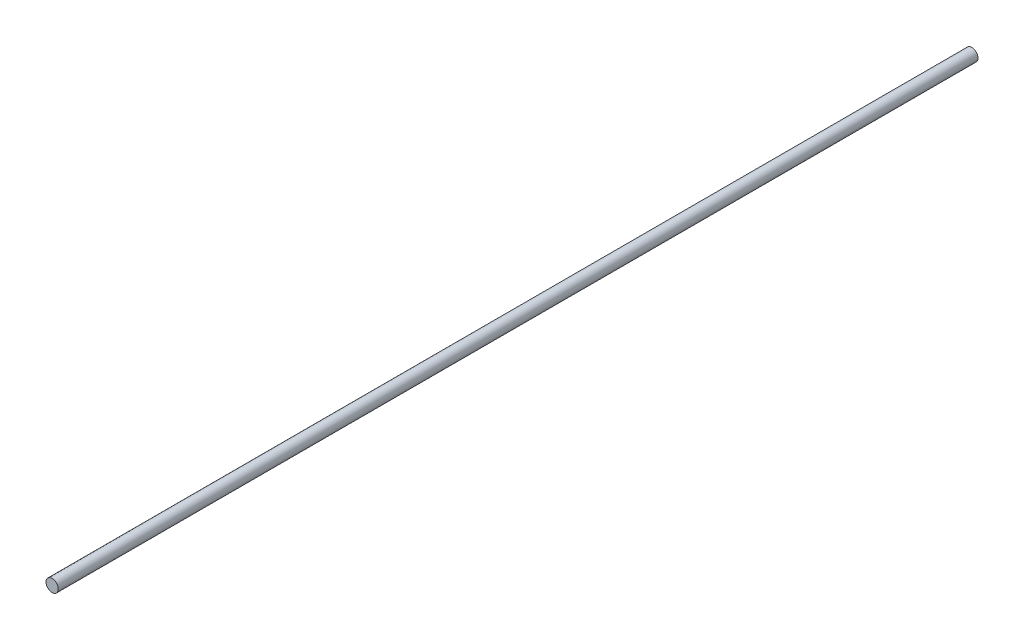
from build123d import *

# Parameters (mm, degrees)
SKETCH_1_R      = 4
EXTRUDE_1_DEPTH = 600


with BuildPart() as part:
    # 草图1 → 凸台-拉伸1 (new body)
    with BuildSketch(Plane.XY):
        Circle(SKETCH_1_R)
    extrude(amount=EXTRUDE_1_DEPTH)


solid = part.part
